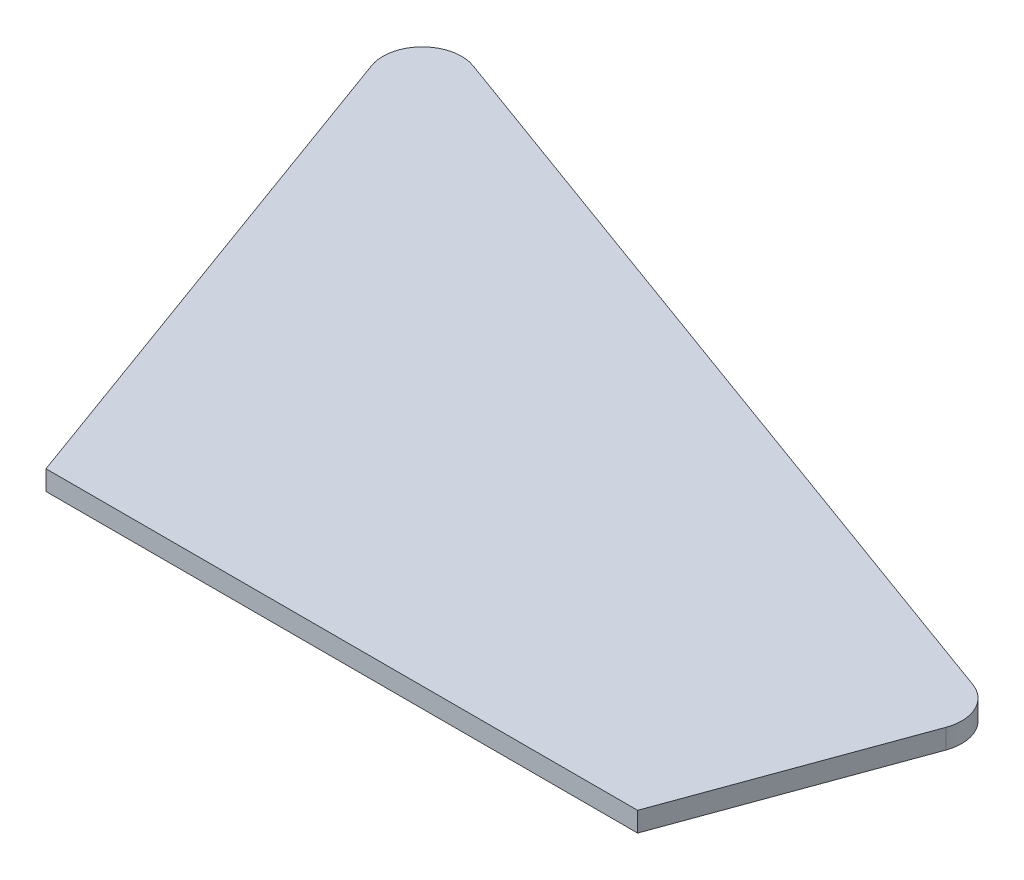
from build123d import *

# Parameters (mm, degrees)
BOSS_EXTRUDE1_DEPTH = 2
BOSS_EXTRUDE2_DEPTH = 2


with BuildPart() as part:
    # Sketch1 → Boss-Extrude1 (new body)
    with BuildSketch(Plane(origin=(0, 0, 0), x_dir=(1, 0, 0), z_dir=(0, 1, 0))):
        with BuildLine():
            Line((-24.718969723, -28.65368563), (35.281030277, -28.65368563))
            Line((35.281030277, -28.65368563), (43.623325522, -5.733417816))
            ThreePointArc((43.623325522, -5.733417816), (43.489786187, -2.674864196), (41.232635612, -0.60656676))
            Line((41.232635612, -0.60656676), (1.368080573, 13.902944676))
            Line((1.368080573, 13.902944676), (-38.496474466, 28.412456113))
            ThreePointArc((-38.496474466, 28.412456113), (-42.692982164, 27.482112755), (-43.623325522, 23.285605056))
            Line((-43.623325522, 23.285605056), (-24.718969723, -28.65368563))
        make_face()
    extrude(amount=BOSS_EXTRUDE1_DEPTH)

    # Sketch3 → Boss-Extrude2 (add)
    with BuildSketch(Plane.XZ):
        with BuildLine():
            Line((-22.26824334, 25.15368563), (-40.334401349, -24.482675558))
            ThreePointArc((-40.334401349, -24.482675558), (-40.21810843, -25.00723902), (-39.693544967, -25.12353194))
            Line((-39.693544967, -25.12353194), (40.035565111, 3.895490933))
            ThreePointArc((40.035565111, 3.895490933), (40.317708932, 4.154028112), (40.334401349, 4.536347315))
            Line((40.334401349, 4.536347315), (32.830303893, 25.15368563))
            Line((32.830303893, 25.15368563), (-22.26824334, 25.15368563))
        make_face()
    extrude(amount=BOSS_EXTRUDE2_DEPTH)


solid = part.part
